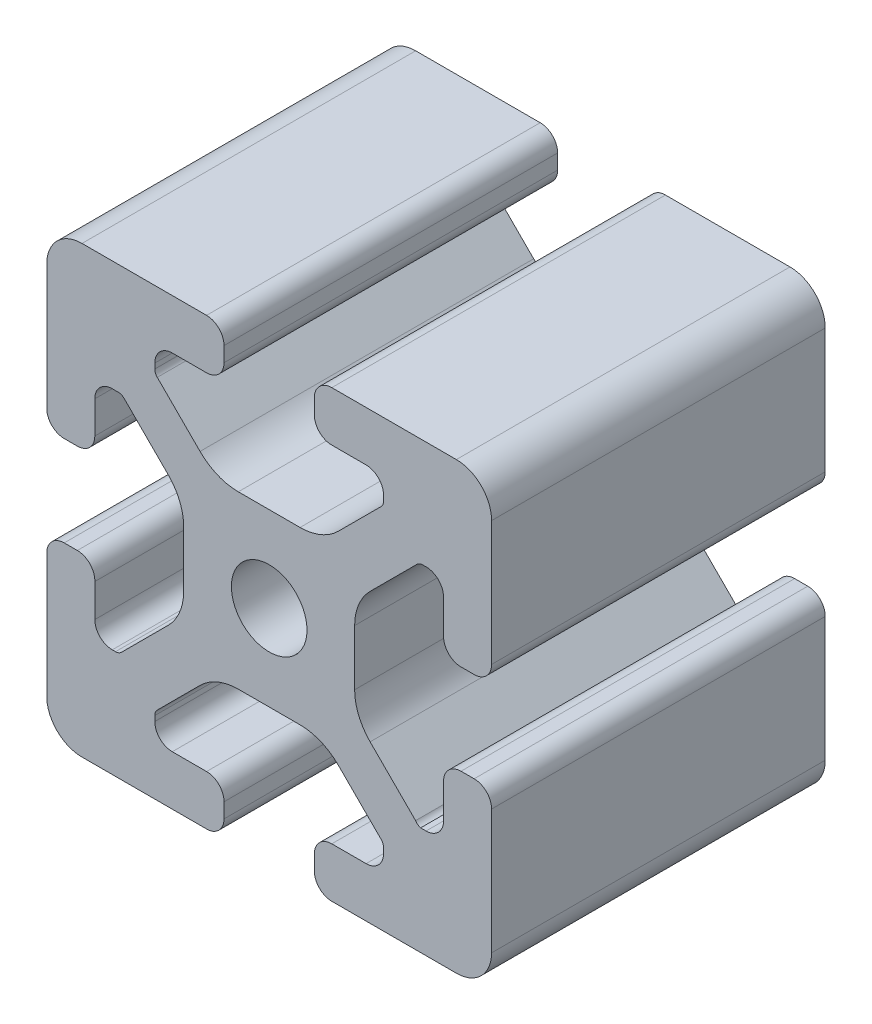
from build123d import *

# Parameters (mm, degrees)
SKETCH1_R      = 3.4
EXTRUDE1_DEPTH = 30


with BuildPart() as part:
    # Sketch1 → Extrude1 (new body)
    with BuildSketch(Plane.XY):
        with BuildLine():
            Line((-8.715, -15.524615034), (-5.63, -15.524615034))
            ThreePointArc((-5.63, -15.524615034), (-4.519842354, -15.984457388), (-4.06, -17.094615034))
            Line((-4.06, -17.094615034), (-4.06, -18.43))
            ThreePointArc((-4.06, -18.43), (-4.519842354, -19.540157646), (-5.63, -20))
            Line((-5.63, -20), (-16.674615034, -20))
            ThreePointArc((-16.674615034, -20), (-18.951578385, -19.194274381), (-20, -17.018368134))
            Line((-20, -17.018368134), (-20, -5.757918808))
            ThreePointArc((-20, -5.757918808), (-19.564709668, -4.603883664), (-18.43, -4.120449326))
            Line((-18.43, -4.120449326), (-17.25, -4.120449326))
            ThreePointArc((-17.25, -4.120449326), (-16.115287682, -4.60388249), (-15.67999625, -5.757919334))
            Line((-15.67999625, -5.757919334), (-15.67999625, -8.715399492))
            ThreePointArc((-15.67999625, -8.715399492), (-15.220153896, -9.825557139), (-14.10999625, -10.285399492))
            Line((-14.10999625, -10.285399492), (-13.816898819, -10.285399492))
            ThreePointArc((-13.816898819, -10.285399492), (-13.526061711, -10.227547119), (-13.279501941, -10.062800646))
            Line((-13.279501941, -10.062800646), (-9.076242789, -5.859541495))
            ThreePointArc((-9.076242789, -5.859541495), (-8.046572221, -4.318530588), (-7.685, -2.500784284))
            Line((-7.685, -2.500784284), (-7.685, 2.500784284))
            ThreePointArc((-7.685, 2.500784284), (-8.046572221, 4.318530588), (-9.076242789, 5.859541495))
            Line((-9.076242789, 5.859541495), (-13.040489136, 9.823787841))
            ThreePointArc((-13.040489136, 9.823787841), (-13.354224618, 10.012729352), (-13.71989919, 10.033001362))
            Line((-13.71989919, 10.033001362), (-14.05520779, 10.044710596))
            ThreePointArc((-14.05520779, 10.044710596), (-15.200613642, 9.605030484), (-15.68, 8.475666998))
            Line((-15.68, 8.475666998), (-15.68, 5.572979049))
            ThreePointArc((-15.68, 5.572979049), (-16.139842354, 4.462821403), (-17.25, 4.002979049))
            Line((-17.25, 4.002979049), (-18.43, 4.002979049))
            ThreePointArc((-18.43, 4.002979049), (-19.540157646, 4.462821403), (-20, 5.572979049))
            Line((-20, 5.572979049), (-20, 13.004526564))
            Line((-20, 13.004526564), (-20, 16.83))
            ThreePointArc((-20, 16.83), (-19.071528496, 19.071528496), (-16.83, 20))
            Line((-16.83, 20), (-5.63, 20))
            ThreePointArc((-5.63, 20), (-4.519842354, 19.540157646), (-4.06, 18.43))
            Line((-4.06, 18.43), (-4.06, 17.094615034))
            ThreePointArc((-4.06, 17.094615034), (-4.519842354, 15.984457388), (-5.63, 15.524615034))
            Line((-5.63, 15.524615034), (-8.715, 15.524615034))
            ThreePointArc((-8.715, 15.524615034), (-9.825157646, 15.06477268), (-10.285, 13.954615034))
            Line((-10.285, 13.954615034), (-10.285, 13.492503602))
            ThreePointArc((-10.285, 13.492503602), (-10.227148445, 13.201664194), (-10.062401154, 12.955102448))
            Line((-10.062401154, 12.955102448), (-6.217092793, 9.109794088))
            ThreePointArc((-6.217092793, 9.109794088), (-4.63891877, 8.055291919), (-2.777335583, 7.685))
            Line((-2.777335583, 7.685), (2.777335583, 7.685))
            ThreePointArc((2.777335583, 7.685), (4.63891877, 8.055291919), (6.217092793, 9.109794088))
            Line((6.217092793, 9.109794088), (10.062401154, 12.955102448))
            ThreePointArc((10.062401154, 12.955102448), (10.227148445, 13.201664194), (10.285, 13.492503602))
            Line((10.285, 13.492503602), (10.285, 13.954615034))
            ThreePointArc((10.285, 13.954615034), (9.825157646, 15.06477268), (8.715, 15.524615034))
            Line((8.715, 15.524615034), (5.63, 15.524615034))
            ThreePointArc((5.63, 15.524615034), (4.519842354, 15.984457388), (4.06, 17.094615034))
            Line((4.06, 17.094615034), (4.06, 18.43))
            ThreePointArc((4.06, 18.43), (4.519842354, 19.540157646), (5.63, 20))
            Line((5.63, 20), (12.979635074, 20))
            Line((12.979635074, 20), (16.83, 20))
            ThreePointArc((16.83, 20), (19.071528496, 19.071528496), (20, 16.83))
            Line((20, 16.83), (20, 13.001098436))
            Line((20, 13.001098436), (20, 5.63))
            ThreePointArc((20, 5.63), (19.540157461, 4.519842693), (18.43, 4.060000526))
            Line((18.43, 4.060000526), (17.24999625, 4.060000526))
            ThreePointArc((17.24999625, 4.060000526), (16.139838603, 4.519842879), (15.67999625, 5.630000526))
            Line((15.67999625, 5.630000526), (15.67999625, 8.715399492))
            ThreePointArc((15.67999625, 8.715399492), (15.220153896, 9.825557139), (14.10999625, 10.285399492))
            Line((14.10999625, 10.285399492), (13.816903094, 10.285399492))
            ThreePointArc((13.816903094, 10.285399492), (13.526063686, 10.227547937), (13.279501941, 10.062800646))
            Line((13.279501941, 10.062800646), (9.076242789, 5.859541495))
            ThreePointArc((9.076242789, 5.859541495), (8.046572221, 4.318530588), (7.685, 2.500784284))
            Line((7.685, 2.500784284), (7.685, -2.500784284))
            ThreePointArc((7.685, -2.500784284), (8.046572221, -4.318530588), (9.076242789, -5.859541495))
            Line((9.076242789, -5.859541495), (13.163657296, -9.946956002))
            ThreePointArc((13.163657296, -9.946956002), (13.35903797, -10.160433474), (13.6200547, -10.285399492))
            Line((13.6200547, -10.285399492), (14.10999625, -10.285399492))
            ThreePointArc((14.10999625, -10.285399492), (15.220153896, -9.825557139), (15.67999625, -8.715399492))
            Line((15.67999625, -8.715399492), (15.67999625, -5.630000526))
            ThreePointArc((15.67999625, -5.630000526), (16.139838603, -4.519842879), (17.24999625, -4.060000526))
            Line((17.24999625, -4.060000526), (18.43, -4.060000526))
            ThreePointArc((18.43, -4.060000526), (19.540157461, -4.519842693), (20, -5.63))
            Line((20, -5.63), (20, -16.83))
            ThreePointArc((20, -16.83), (19.071528496, -19.071528496), (16.83, -20))
            Line((16.83, -20), (13, -20))
            Line((13, -20), (5.63, -20))
            ThreePointArc((5.63, -20), (4.519842354, -19.540157646), (4.06, -18.43))
            Line((4.06, -18.43), (4.06, -17.094615034))
            ThreePointArc((4.06, -17.094615034), (4.519842354, -15.984457388), (5.63, -15.524615034))
            Line((5.63, -15.524615034), (8.715, -15.524615034))
            ThreePointArc((8.715, -15.524615034), (9.825157646, -15.06477268), (10.285, -13.954615034))
            Line((10.285, -13.954615034), (10.285, -13.492503602))
            ThreePointArc((10.285, -13.492503602), (10.227148445, -13.201664194), (10.062401154, -12.955102448))
            Line((10.062401154, -12.955102448), (6.217092793, -9.109794088))
            ThreePointArc((6.217092793, -9.109794088), (4.63891877, -8.055291919), (2.777335583, -7.685))
            Line((2.777335583, -7.685), (-2.777335583, -7.685))
            ThreePointArc((-2.777335583, -7.685), (-4.63891877, -8.055291919), (-6.217092793, -9.109794088))
            Line((-6.217092793, -9.109794088), (-10.062401154, -12.955102448))
            ThreePointArc((-10.062401154, -12.955102448), (-10.227148445, -13.201664194), (-10.285, -13.492503602))
            Line((-10.285, -13.492503602), (-10.285, -13.954615034))
            ThreePointArc((-10.285, -13.954615034), (-9.825157646, -15.06477268), (-8.715, -15.524615034))
        make_face()
        Circle(SKETCH1_R, mode=Mode.SUBTRACT)
    extrude(amount=-EXTRUDE1_DEPTH)


solid = part.part
